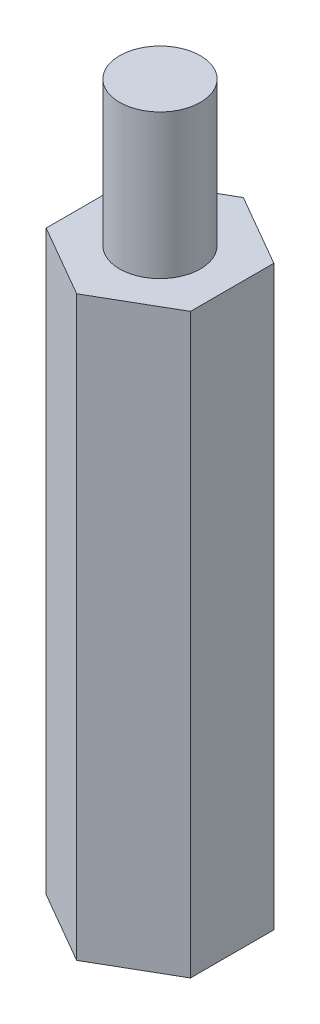
from build123d import *

# Parameters (mm, degrees)
BOSS_EXTRUDE1_DEPTH = 25.4
SKETCH2_R           = 1.778
BOSS_EXTRUDE2_DEPTH = 6.35


with BuildPart() as part:
    # Sketch1 → Boss-Extrude1 (new body)
    with BuildSketch(Plane(origin=(0, 0, 0), x_dir=(1, 0, 0), z_dir=(0, 1, 0))):
        Polygon((0, 3.666174209), (-3.175, 1.833087105), (-3.175, -1.833087105), (0, -3.666174209), (3.175, -1.833087105), (3.175, 1.833087105), align=None)
    extrude(amount=BOSS_EXTRUDE1_DEPTH)

    # Sketch2 → Boss-Extrude2 (add)
    with BuildSketch(Plane(origin=(0, 25.4, 0), x_dir=(1, 0, 0), z_dir=(0, 1, 0))):
        Circle(SKETCH2_R)
    extrude(amount=BOSS_EXTRUDE2_DEPTH)


solid = part.part
